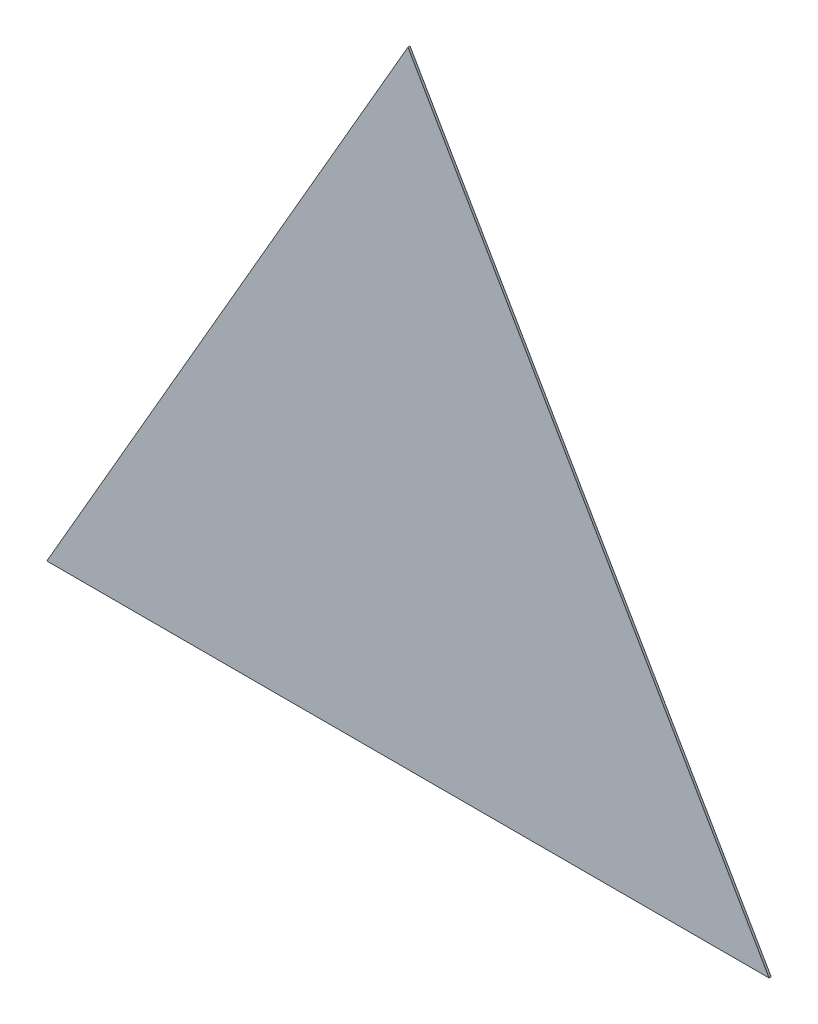
from build123d import *

# Parameters (mm, degrees)
EXTRUDE_1_DEPTH = 2


with BuildPart() as part:
    # Эскиз1 → Бобышка-Вытянуть1 (new body)
    with BuildSketch(Plane.XY):
        Polygon((0, 400), (-346.410161514, -200), (346.410161514, -200), align=None)
    extrude(amount=EXTRUDE_1_DEPTH)


solid = part.part
